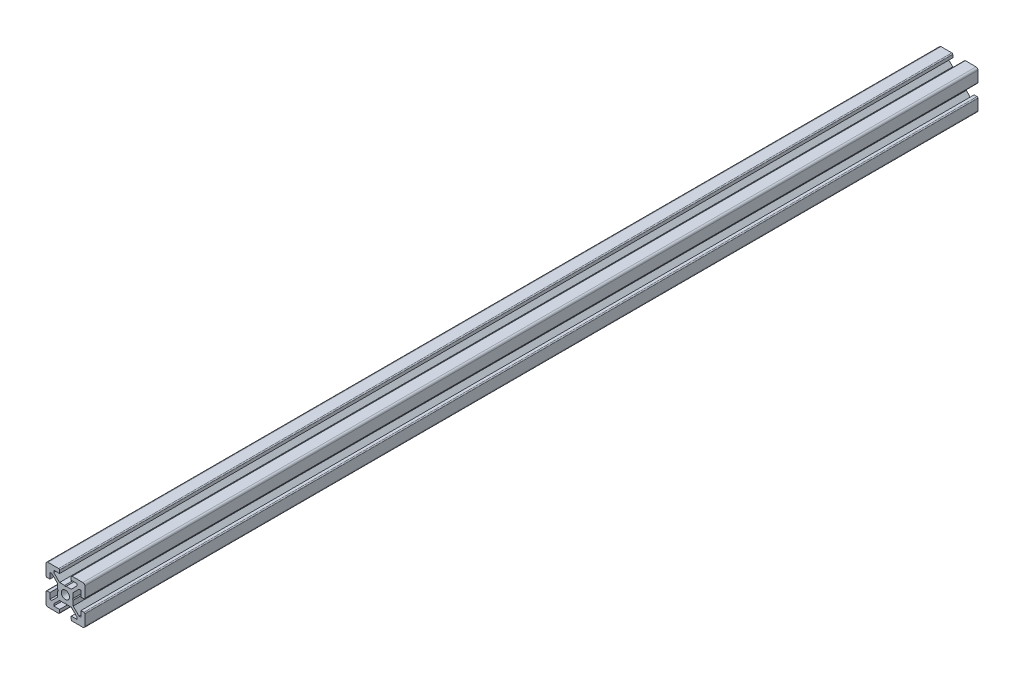
from build123d import *

# Parameters (mm, degrees)
SCHIZZO1_R                   = 2.1
ESTRUSIONE_ESTRUSIONE1_DEPTH = 460
SCHIZZO2_R                   = 3
TAGLIO_ESTRUSIONE1_DEPTH     = 15


with BuildPart() as part:
    # Schizzo1 → Estrusione-Estrusione1 (new body)
    with BuildSketch(Plane.XY):
        with BuildLine():
            Line((-3.6, 0), (-4, 0.4))
            Line((-4, 0.4), (-4, 3))
            Line((-4, 3), (-7, 6))
            Line((-7, 6), (-8, 6))
            Line((-8, 6), (-8, 3))
            Line((-8, 3), (-9.5, 3))
            ThreePointArc((-9.5, 3), (-9.853553391, 3.146446609), (-10, 3.5))
            Line((-10, 3.5), (-10, 9))
            ThreePointArc((-10, 9), (-9.707106781, 9.707106781), (-9, 10))
            Line((-9, 10), (-3.5, 10))
            ThreePointArc((-3.5, 10), (-3.146446609, 9.853553391), (-3, 9.5))
            Line((-3, 9.5), (-3, 8))
            Line((-3, 8), (-6, 8))
            Line((-6, 8), (-6, 7))
            Line((-6, 7), (-3, 4))
            Line((-3, 4), (-0.4, 4))
            Line((-0.4, 4), (0, 3.6))
            Line((0, 3.6), (0.4, 4))
            Line((0.4, 4), (3, 4))
            Line((3, 4), (6, 7))
            Line((6, 7), (6, 8))
            Line((6, 8), (3, 8))
            Line((3, 8), (3, 9.5))
            ThreePointArc((3, 9.5), (3.146446609, 9.853553391), (3.5, 10))
            Line((3.5, 10), (9, 10))
            ThreePointArc((9, 10), (9.707106781, 9.707106781), (10, 9))
            Line((10, 9), (10, 3.5))
            ThreePointArc((10, 3.5), (9.853553391, 3.146446609), (9.5, 3))
            Line((9.5, 3), (8, 3))
            Line((8, 3), (8, 6))
            Line((8, 6), (7, 6))
            Line((7, 6), (4, 3))
            Line((4, 3), (4, 0.4))
            Line((4, 0.4), (3.6, 0))
            Line((3.6, 0), (4, -0.4))
            Line((4, -0.4), (4, -3))
            Line((4, -3), (7, -6))
            Line((7, -6), (8, -6))
            Line((8, -6), (8, -3))
            Line((8, -3), (9.5, -3))
            ThreePointArc((9.5, -3), (9.853553391, -3.146446609), (10, -3.5))
            Line((10, -3.5), (10, -9))
            ThreePointArc((10, -9), (9.707106781, -9.707106781), (9, -10))
            Line((9, -10), (3.5, -10))
            ThreePointArc((3.5, -10), (3.146446609, -9.853553391), (3, -9.5))
            Line((3, -9.5), (3, -8))
            Line((3, -8), (6, -8))
            Line((6, -8), (6, -7))
            Line((6, -7), (3, -4))
            Line((3, -4), (0.4, -4))
            Line((0.4, -4), (0, -3.6))
            Line((0, -3.6), (-0.4, -4))
            Line((-0.4, -4), (-3, -4))
            Line((-3, -4), (-6, -7))
            Line((-6, -7), (-6, -8))
            Line((-6, -8), (-3, -8))
            Line((-3, -8), (-3, -9.5))
            ThreePointArc((-3, -9.5), (-3.146446609, -9.853553391), (-3.5, -10))
            Line((-3.5, -10), (-9, -10))
            ThreePointArc((-9, -10), (-9.707106781, -9.707106781), (-10, -9))
            Line((-10, -9), (-10, -3.5))
            ThreePointArc((-10, -3.5), (-9.853553391, -3.146446609), (-9.5, -3))
            Line((-9.5, -3), (-8, -3))
            Line((-8, -3), (-8, -6))
            Line((-8, -6), (-7, -6))
            Line((-7, -6), (-4, -3))
            Line((-4, -3), (-4, -0.4))
            Line((-4, -0.4), (-3.6, 0))
        make_face()
        Circle(SCHIZZO1_R, mode=Mode.SUBTRACT)
    extrude(amount=ESTRUSIONE_ESTRUSIONE1_DEPTH)

    # Schizzo2 → Taglio-Estrusione1 (cut, through all)
    with BuildSketch(Plane.ZY.offset(4)):
        with Locations((25, 0)):
            Circle(SCHIZZO2_R)
        with Locations((435, 0)):
            Circle(SCHIZZO2_R)
    extrude(amount=-TAGLIO_ESTRUSIONE1_DEPTH, mode=Mode.SUBTRACT)


solid = part.part
